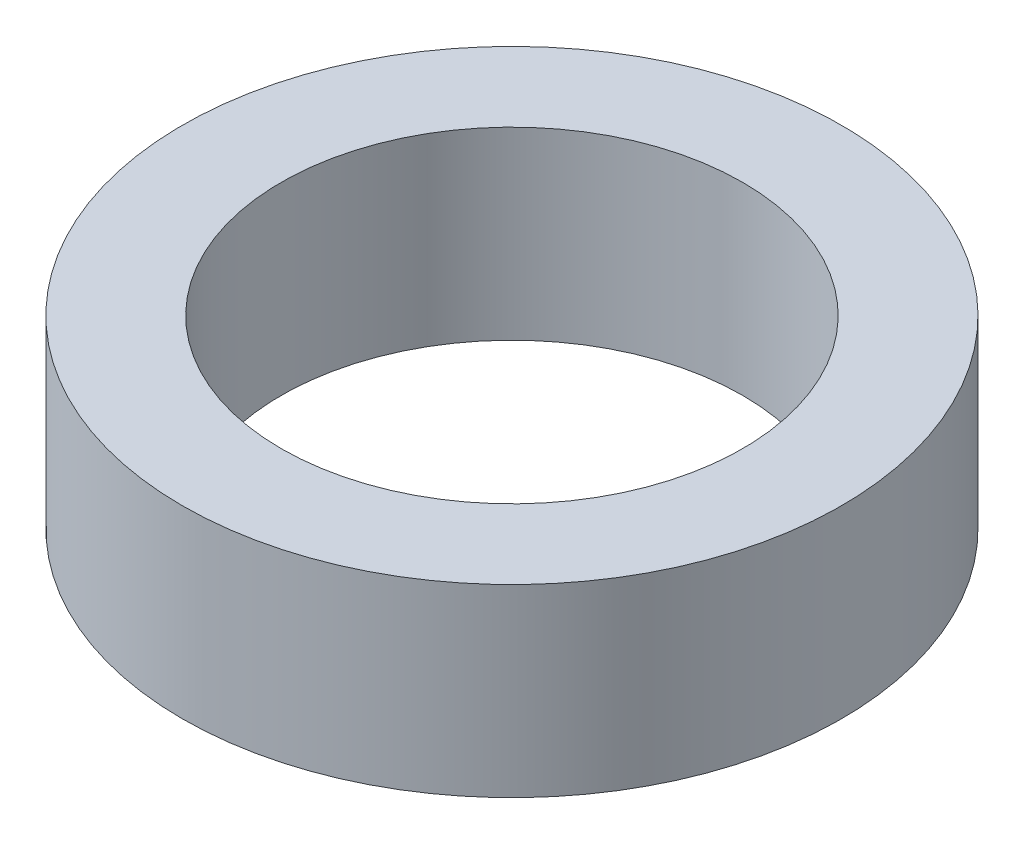
from build123d import *

# Parameters (mm, degrees)
SKETCH1_R           = 12.7
SKETCH1_R_2         = 8.89
BOSS_EXTRUDE1_DEPTH = 7.112


with BuildPart() as part:
    # Sketch1 → Boss-Extrude1 (new body)
    with BuildSketch(Plane(origin=(0, 0, 0), x_dir=(1, 0, 0), z_dir=(0, 1, 0))):
        Circle(SKETCH1_R)
        Circle(SKETCH1_R_2, mode=Mode.SUBTRACT)
    extrude(amount=BOSS_EXTRUDE1_DEPTH)


solid = part.part
